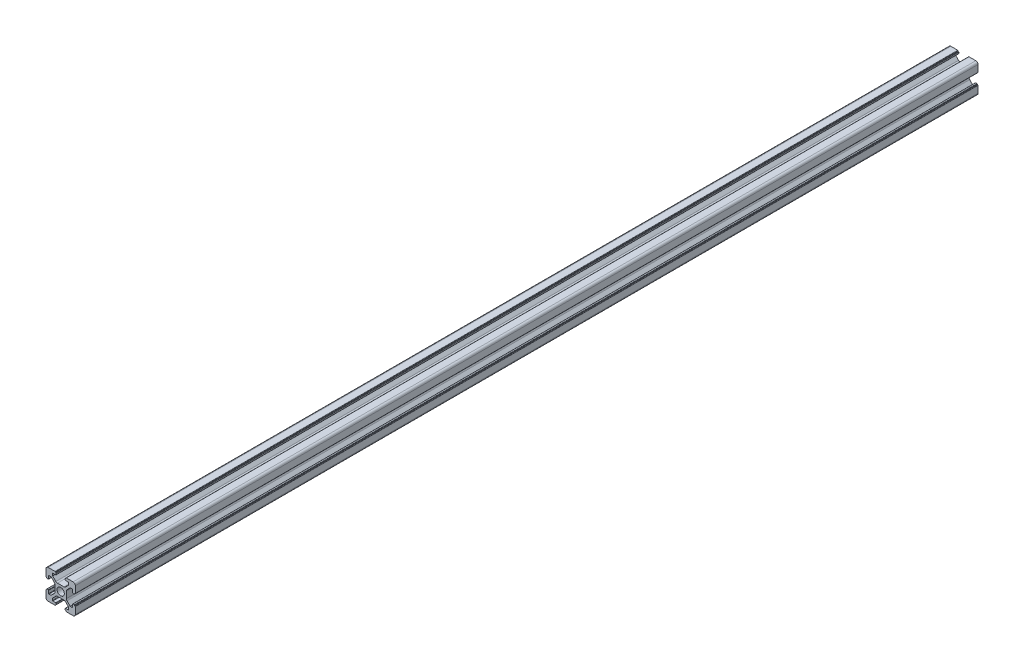
from build123d import *

# Parameters (mm, degrees)
SKETCH_1_R      = 2.5
EXTRUDE_1_DEPTH = 616


with BuildPart() as part:
    # 草图1 → 凸台-拉伸1 (new body)
    with BuildSketch(Plane.XY):
        with BuildLine():
            Line((-8.502261885, -10.002261885), (-3.85, -10.002261885))
            ThreePointArc((-3.85, -10.002261885), (-3.673223305, -9.929038581), (-3.6, -9.752261885))
            Line((-3.6, -9.752261885), (-3.6, -9.502261885))
            Line((-3.6, -9.502261885), (-3.35, -9.502261885))
            ThreePointArc((-3.35, -9.502261885), (-3.173223305, -9.429038581), (-3.1, -9.252261885))
            Line((-3.1, -9.252261885), (-3.1, -8.45))
            ThreePointArc((-3.1, -8.45), (-3.173223305, -8.273223305), (-3.35, -8.2))
            Line((-3.35, -8.2), (-5.25, -8.2))
            ThreePointArc((-5.25, -8.2), (-5.426776695, -8.126776695), (-5.5, -7.95))
            Line((-5.5, -7.95), (-5.5, -6.664213562))
            ThreePointArc((-5.5, -6.664213562), (-5.480969883, -6.568542704), (-5.426776695, -6.487436867))
            Line((-5.426776695, -6.487436867), (-3.278679656, -4.339339828))
            ThreePointArc((-3.278679656, -4.339339828), (-2.792044633, -4.014180701), (-2.218019485, -3.9))
            Line((-2.218019485, -3.9), (2.218019485, -3.9))
            ThreePointArc((2.218019485, -3.9), (2.792044633, -4.014180701), (3.278679656, -4.339339828))
            Line((3.278679656, -4.339339828), (5.426776695, -6.487436867))
            ThreePointArc((5.426776695, -6.487436867), (5.480969883, -6.568542704), (5.5, -6.664213562))
            Line((5.5, -6.664213562), (5.5, -7.95))
            ThreePointArc((5.5, -7.95), (5.426776695, -8.126776695), (5.25, -8.2))
            Line((5.25, -8.2), (3.35, -8.2))
            ThreePointArc((3.35, -8.2), (3.173223305, -8.273223305), (3.1, -8.45))
            Line((3.1, -8.45), (3.1, -9.252261885))
            ThreePointArc((3.1, -9.252261885), (3.173223305, -9.429038581), (3.35, -9.502261885))
            Line((3.35, -9.502261885), (3.6, -9.502261885))
            Line((3.6, -9.502261885), (3.6, -9.752261885))
            ThreePointArc((3.6, -9.752261885), (3.673223305, -9.929038581), (3.85, -10.002261885))
            Line((3.85, -10.002261885), (8.502261885, -10.002261885))
            ThreePointArc((8.502261885, -10.002261885), (9.562922057, -9.562922057), (10.002261885, -8.502261885))
            Line((10.002261885, -8.502261885), (10.002261885, -3.85))
            ThreePointArc((10.002261885, -3.85), (9.929038581, -3.673223305), (9.752261885, -3.6))
            Line((9.752261885, -3.6), (9.502261885, -3.6))
            Line((9.502261885, -3.6), (9.502261885, -3.35))
            ThreePointArc((9.502261885, -3.35), (9.429038581, -3.173223305), (9.252261885, -3.1))
            Line((9.252261885, -3.1), (8.45, -3.1))
            ThreePointArc((8.45, -3.1), (8.273223305, -3.173223305), (8.2, -3.35))
            Line((8.2, -3.35), (8.2, -5.25))
            ThreePointArc((8.2, -5.25), (8.126776695, -5.426776695), (7.95, -5.5))
            Line((7.95, -5.5), (6.664213562, -5.5))
            ThreePointArc((6.664213562, -5.5), (6.568542704, -5.480969883), (6.487436867, -5.426776695))
            Line((6.487436867, -5.426776695), (4.339339828, -3.278679656))
            ThreePointArc((4.339339828, -3.278679656), (4.014180701, -2.792044633), (3.9, -2.218019485))
            Line((3.9, -2.218019485), (3.9, 2.218019485))
            ThreePointArc((3.9, 2.218019485), (4.014180701, 2.792044633), (4.339339828, 3.278679656))
            Line((4.339339828, 3.278679656), (6.487436867, 5.426776695))
            ThreePointArc((6.487436867, 5.426776695), (6.568542704, 5.480969883), (6.664213562, 5.5))
            Line((6.664213562, 5.5), (7.95, 5.5))
            ThreePointArc((7.95, 5.5), (8.126776695, 5.426776695), (8.2, 5.25))
            Line((8.2, 5.25), (8.2, 3.35))
            ThreePointArc((8.2, 3.35), (8.273223305, 3.173223305), (8.45, 3.1))
            Line((8.45, 3.1), (9.252261885, 3.1))
            ThreePointArc((9.252261885, 3.1), (9.429038581, 3.173223305), (9.502261885, 3.35))
            Line((9.502261885, 3.35), (9.502261885, 3.6))
            Line((9.502261885, 3.6), (9.752261885, 3.6))
            ThreePointArc((9.752261885, 3.6), (9.929038581, 3.673223305), (10.002261885, 3.85))
            Line((10.002261885, 3.85), (10.002261885, 8.502261885))
            ThreePointArc((10.002261885, 8.502261885), (9.562922057, 9.562922057), (8.502261885, 10.002261885))
            Line((8.502261885, 10.002261885), (3.85, 10.002261885))
            ThreePointArc((3.85, 10.002261885), (3.673223305, 9.929038581), (3.6, 9.752261885))
            Line((3.6, 9.752261885), (3.6, 9.502261885))
            Line((3.6, 9.502261885), (3.35, 9.502261885))
            ThreePointArc((3.35, 9.502261885), (3.173223305, 9.429038581), (3.1, 9.252261885))
            Line((3.1, 9.252261885), (3.1, 8.45))
            ThreePointArc((3.1, 8.45), (3.173223305, 8.273223305), (3.35, 8.2))
            Line((3.35, 8.2), (5.25, 8.2))
            ThreePointArc((5.25, 8.2), (5.426776695, 8.126776695), (5.5, 7.95))
            Line((5.5, 7.95), (5.5, 6.664213562))
            ThreePointArc((5.5, 6.664213562), (5.480969883, 6.568542704), (5.426776695, 6.487436867))
            Line((5.426776695, 6.487436867), (3.278679656, 4.339339828))
            ThreePointArc((3.278679656, 4.339339828), (2.792044633, 4.014180701), (2.218019485, 3.9))
            Line((2.218019485, 3.9), (-2.218019485, 3.9))
            ThreePointArc((-2.218019485, 3.9), (-2.792044633, 4.014180701), (-3.278679656, 4.339339828))
            Line((-3.278679656, 4.339339828), (-5.426776695, 6.487436867))
            ThreePointArc((-5.426776695, 6.487436867), (-5.480969883, 6.568542704), (-5.5, 6.664213562))
            Line((-5.5, 6.664213562), (-5.5, 7.95))
            ThreePointArc((-5.5, 7.95), (-5.426776695, 8.126776695), (-5.25, 8.2))
            Line((-5.25, 8.2), (-3.35, 8.2))
            ThreePointArc((-3.35, 8.2), (-3.173223305, 8.273223305), (-3.1, 8.45))
            Line((-3.1, 8.45), (-3.1, 9.252261885))
            ThreePointArc((-3.1, 9.252261885), (-3.173223305, 9.429038581), (-3.35, 9.502261885))
            Line((-3.35, 9.502261885), (-3.6, 9.502261885))
            Line((-3.6, 9.502261885), (-3.6, 9.752261885))
            ThreePointArc((-3.6, 9.752261885), (-3.673223305, 9.929038581), (-3.85, 10.002261885))
            Line((-3.85, 10.002261885), (-8.502261885, 10.002261885))
            ThreePointArc((-8.502261885, 10.002261885), (-9.562922057, 9.562922057), (-10.002261885, 8.502261885))
            Line((-10.002261885, 8.502261885), (-10.002261885, 3.85))
            ThreePointArc((-10.002261885, 3.85), (-9.929038581, 3.673223305), (-9.752261885, 3.6))
            Line((-9.752261885, 3.6), (-9.502261885, 3.6))
            Line((-9.502261885, 3.6), (-9.502261885, 3.35))
            ThreePointArc((-9.502261885, 3.35), (-9.429038581, 3.173223305), (-9.252261885, 3.1))
            Line((-9.252261885, 3.1), (-8.45, 3.1))
            ThreePointArc((-8.45, 3.1), (-8.273223305, 3.173223305), (-8.2, 3.35))
            Line((-8.2, 3.35), (-8.2, 5.25))
            ThreePointArc((-8.2, 5.25), (-8.126776695, 5.426776695), (-7.95, 5.5))
            Line((-7.95, 5.5), (-6.664213562, 5.5))
            ThreePointArc((-6.664213562, 5.5), (-6.568542704, 5.480969883), (-6.487436867, 5.426776695))
            Line((-6.487436867, 5.426776695), (-4.339339828, 3.278679656))
            ThreePointArc((-4.339339828, 3.278679656), (-4.014180701, 2.792044633), (-3.9, 2.218019485))
            Line((-3.9, 2.218019485), (-3.9, -2.218019485))
            ThreePointArc((-3.9, -2.218019485), (-4.014180701, -2.792044633), (-4.339339828, -3.278679656))
            Line((-4.339339828, -3.278679656), (-6.487436867, -5.426776695))
            ThreePointArc((-6.487436867, -5.426776695), (-6.568542704, -5.480969883), (-6.664213562, -5.5))
            Line((-6.664213562, -5.5), (-7.95, -5.5))
            ThreePointArc((-7.95, -5.5), (-8.126776695, -5.426776695), (-8.2, -5.25))
            Line((-8.2, -5.25), (-8.2, -3.35))
            ThreePointArc((-8.2, -3.35), (-8.273223305, -3.173223305), (-8.45, -3.1))
            Line((-8.45, -3.1), (-9.252261885, -3.1))
            ThreePointArc((-9.252261885, -3.1), (-9.429038581, -3.173223305), (-9.502261885, -3.35))
            Line((-9.502261885, -3.35), (-9.502261885, -3.6))
            Line((-9.502261885, -3.6), (-9.752261885, -3.6))
            ThreePointArc((-9.752261885, -3.6), (-9.929038581, -3.673223305), (-10.002261885, -3.85))
            Line((-10.002261885, -3.85), (-10.002261885, -8.502261885))
            ThreePointArc((-10.002261885, -8.502261885), (-9.562922057, -9.562922057), (-8.502261885, -10.002261885))
        make_face()
        Circle(SKETCH_1_R, mode=Mode.SUBTRACT)
    extrude(amount=EXTRUDE_1_DEPTH)


solid = part.part
